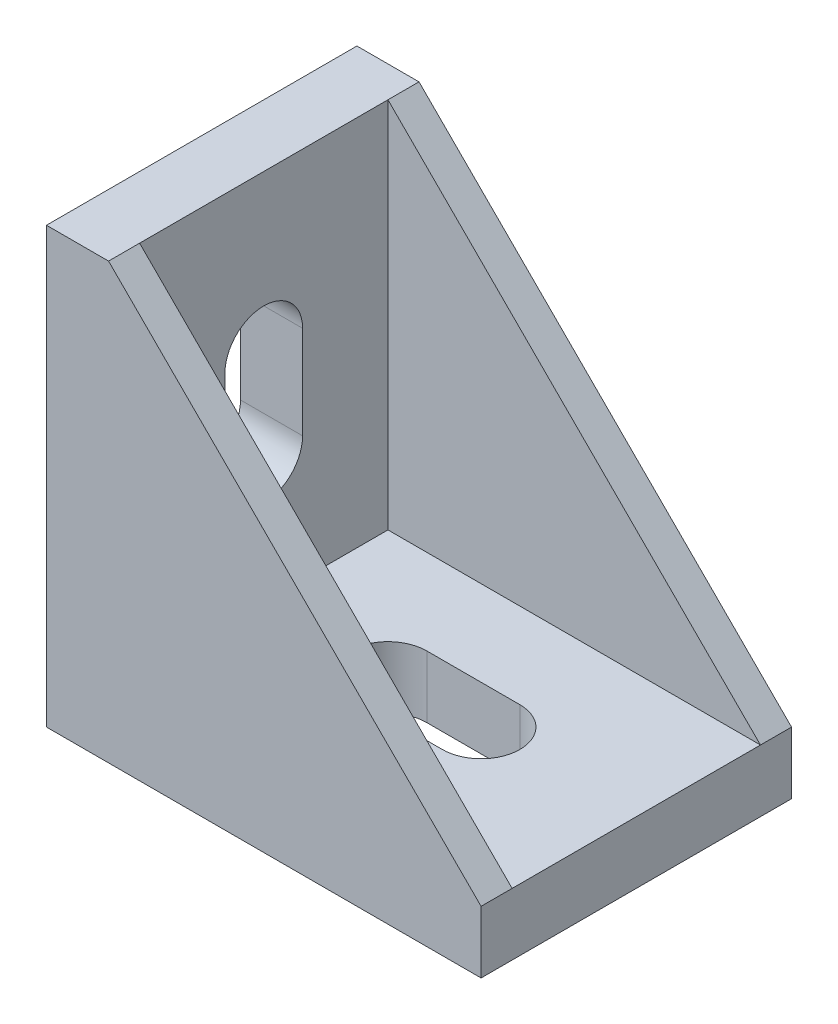
from build123d import *

# Parameters (mm, degrees)
EXTRUDE_1_DEPTH     = 10
EXTRUDE_2_DEPTH     = 2
CUT_EXTRUDE_1_DEPTH = 5
SKETCH_4_W          = 2.5
SKETCH_4_H          = 6
EXTRUDE_3_DEPTH     = 2.5


with BuildPart() as part:
    # Эскиз1 → Бобышка-Вытянуть1 (new body, symmetric)
    with BuildSketch(Plane.XY):
        Polygon((0, 28), (0, 0), (28, 0), (28, 4), (4, 4), (4, 28), align=None)
    extrude(amount=EXTRUDE_1_DEPTH, both=True)

    # Эскиз2 → Бобышка-Вытянуть2 (add)
    with BuildSketch(Plane.XY.offset(10)):
        Polygon((4, 28), (28, 4), (4, 4), align=None)
    extrude_2 = extrude(amount=-EXTRUDE_2_DEPTH)

    # Зеркальное отражение2: Бобышка-Вытянуть2 across plane
    add(extrude_2.mirror(Plane.XY))

    # Эскиз3 → Вырез-Вытянуть1 (cut, through all)
    with BuildSketch(Plane(origin=(0, 4, 0), x_dir=(1, 0, 0), z_dir=(0, 1, 0))):
        with BuildLine():
            Line((12, 2.5), (18, 2.5))
            ThreePointArc((18, 2.5), (20.5, 0), (18, -2.5))
            Line((18, -2.5), (12, -2.5))
            ThreePointArc((12, -2.5), (9.5, 0), (12, 2.5))
        make_face()
    cut_extrude_1 = extrude(amount=-CUT_EXTRUDE_1_DEPTH, mode=Mode.SUBTRACT)

    # Эскиз4 → Бобышка-Вытянуть3 (add)
    with BuildSketch(Plane.XZ):
        with Locations((4.25, 0)):
            Rectangle(SKETCH_4_W, SKETCH_4_H)
        with Locations((23.75, 0)):
            Rectangle(SKETCH_4_W, SKETCH_4_H)
    extrude_3 = extrude(amount=EXTRUDE_3_DEPTH)

    # Зеркальное отражение3: Вырез-Вытянуть1, Бобышка-Вытянуть3 across plane
    add(cut_extrude_1.mirror(Plane(origin=(0, 0, 0), x_dir=(0, 0, 1), z_dir=(-0.707106781, 0.707106781, 0))), mode=Mode.SUBTRACT)
    add(extrude_3.mirror(Plane(origin=(0, 0, 0), x_dir=(0, 0, 1), z_dir=(-0.707106781, 0.707106781, 0))))


solid = part.part
